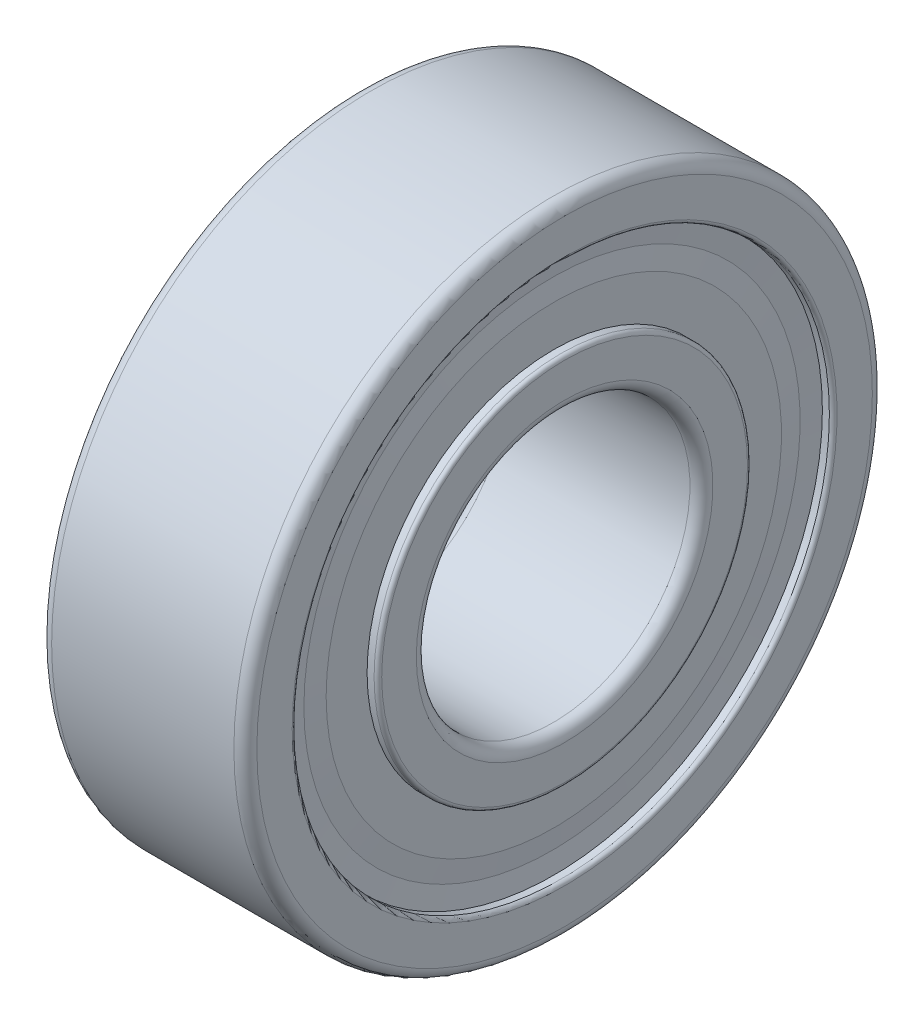
from build123d import *


with BuildPart() as part:
    # Sketch1 → Revolve1 (revolve)
    with BuildSketch(Plane(origin=(0, 0, 0), x_dir=(-1, 0, 0), z_dir=(0, 0, -1))):
        with BuildLine():
            Line((-6.744, 4.763), (-0.4, 4.763))
            ThreePointArc((-0.4, 4.763), (-0.117157288, 4.880157288), (0, 5.163))
            Line((0, 5.163), (0, 6.367))
            ThreePointArc((0, 6.367), (-0.038954798, 6.461045202), (-0.133, 6.5))
            Line((-0.133, 6.5), (-0.376, 6.5))
            Line((-0.376, 6.5), (-0.376, 7.925))
            Line((-0.376, 7.925), (-0.43875, 8.6375))
            Line((-0.43875, 8.6375), (-0.376, 9.35))
            Line((-0.376, 9.35), (-0.133, 9.35))
            ThreePointArc((-0.133, 9.35), (-0.038954798, 9.388954798), (0, 9.483))
            Line((0, 9.483), (0, 10.713))
            ThreePointArc((0, 10.713), (-0.117157288, 10.995842712), (-0.4, 11.113))
            Line((-0.4, 11.113), (-6.744, 11.113))
            ThreePointArc((-6.744, 11.113), (-7.026842712, 10.995842712), (-7.144, 10.713))
            Line((-7.144, 10.713), (-7.144, 9.483))
            ThreePointArc((-7.144, 9.483), (-7.105045202, 9.388954798), (-7.011, 9.35))
            Line((-7.011, 9.35), (-6.768, 9.35))
            Line((-6.768, 9.35), (-6.70525, 8.6375))
            Line((-6.70525, 8.6375), (-6.768, 7.925))
            Line((-6.768, 7.925), (-6.768, 6.5))
            Line((-6.768, 6.5), (-7.011, 6.5))
            ThreePointArc((-7.011, 6.5), (-7.105045202, 6.461045202), (-7.144, 6.367))
            Line((-7.144, 6.367), (-7.144, 5.163))
            ThreePointArc((-7.144, 5.163), (-7.026842712, 4.880157288), (-6.744, 4.763))
        make_face()
    revolve(axis=Axis((7.147771597, 0, 0), (-1, 0, 0)))


solid = part.part
